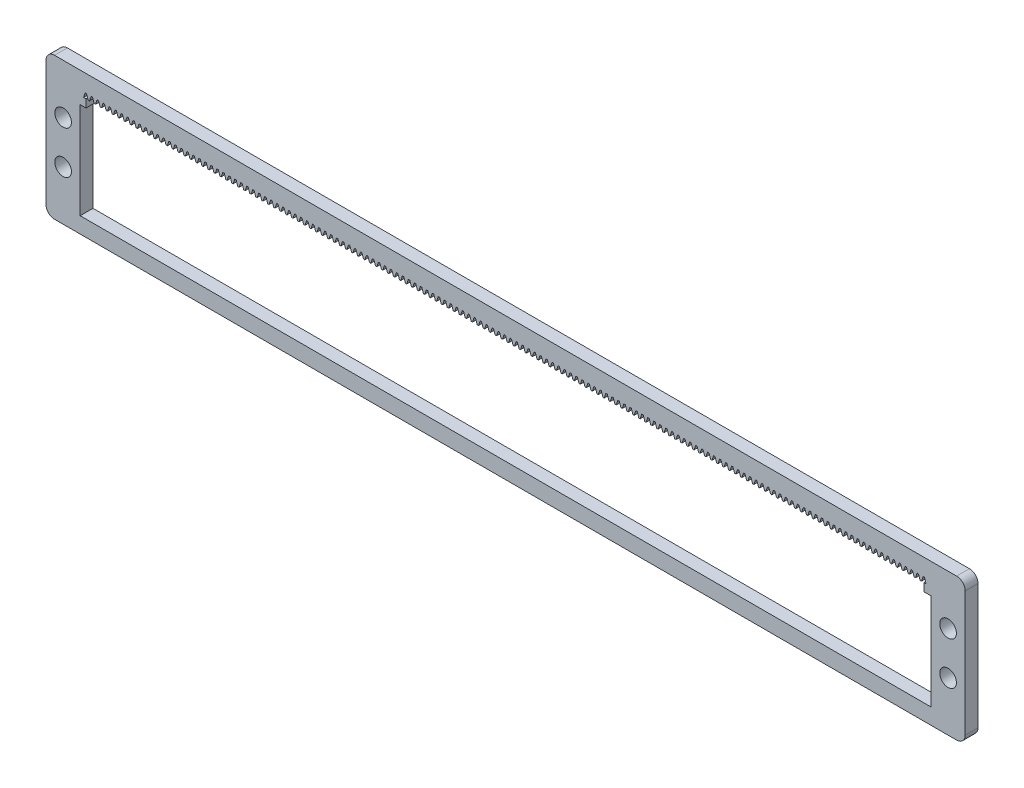
from build123d import *

# Parameters (mm, degrees)
BOSS_EXTRUDE1_DEPTH = 3
SKETCH2_W           = 199
SKETCH2_H           = 22.5
CUT_EXTRUDE1_DEPTH  = 4
SKETCH3_W           = 195.97
SKETCH3_H           = 1.85
CUT_EXTRUDE2_DEPTH  = 4
CUT_EXTRUDE4_DEPTH  = 4
LPATTERN1_COUNT     = 141
LPATTERN1_PITCH     = 1.4
SKETCH5_R           = 1.95
CUT_EXTRUDE5_DEPTH  = 10


with BuildPart() as part:
    # Sketch1 → Boss-Extrude1 (new body)
    with BuildSketch(Plane.XY):
        with BuildLine():
            Line((2, 0), (213, 0))
            ThreePointArc((213, 0), (214.414213562, -0.585786438), (215, -2))
            Line((215, -2), (215, -31.22))
            ThreePointArc((215, -31.22), (214.414213562, -32.634213562), (213, -33.22))
            Line((213, -33.22), (2, -33.22))
            ThreePointArc((2, -33.22), (0.585786438, -32.634213562), (0, -31.22))
            Line((0, -31.22), (0, -2))
            ThreePointArc((0, -2), (0.585786438, -0.585786438), (2, 0))
        make_face()
    extrude(amount=BOSS_EXTRUDE1_DEPTH)

    # Sketch2 → Cut-Extrude1 (cut, through all)
    with BuildSketch(Plane.XY.offset(3)):
        with Locations((107.5, -18.25)):
            Rectangle(SKETCH2_W, SKETCH2_H)
    extrude(amount=-CUT_EXTRUDE1_DEPTH, mode=Mode.SUBTRACT)

    # Sketch3 → Cut-Extrude2 (cut, through all)
    with BuildSketch(Plane.XY.offset(3)):
        with Locations((107.335, -6.075)):
            Rectangle(SKETCH3_W, SKETCH3_H)
    extrude(amount=-CUT_EXTRUDE2_DEPTH, mode=Mode.SUBTRACT)

    # Sketch4 → Cut-Extrude4 (cut, through all)
    with BuildSketch(Plane.XY.offset(3)):
        Polygon((205.485, -4.011755738), (205.865, -5.15), (204.775, -5.15), (205.155, -4.011755738), align=None)
    cut_extrude4 = extrude(amount=-CUT_EXTRUDE4_DEPTH, mode=Mode.SUBTRACT)

    # LPattern1: Cut-Extrude4 ×141
    with Locations(*[(-i * LPATTERN1_PITCH, 0, 0) for i in range(1, LPATTERN1_COUNT)]):
        add(cut_extrude4, mode=Mode.SUBTRACT)

    # Sketch5 → Cut-Extrude5 (cut)
    with BuildSketch(Plane.XY.offset(3)):
        with Locations((4, -11.61)):
            Circle(SKETCH5_R)
        with Locations((4, -21.61)):
            Circle(SKETCH5_R)
        with Locations((211, -11.61)):
            Circle(SKETCH5_R)
        with Locations((211, -21.61)):
            Circle(SKETCH5_R)
    extrude(amount=-CUT_EXTRUDE5_DEPTH, mode=Mode.SUBTRACT)


solid = part.part
